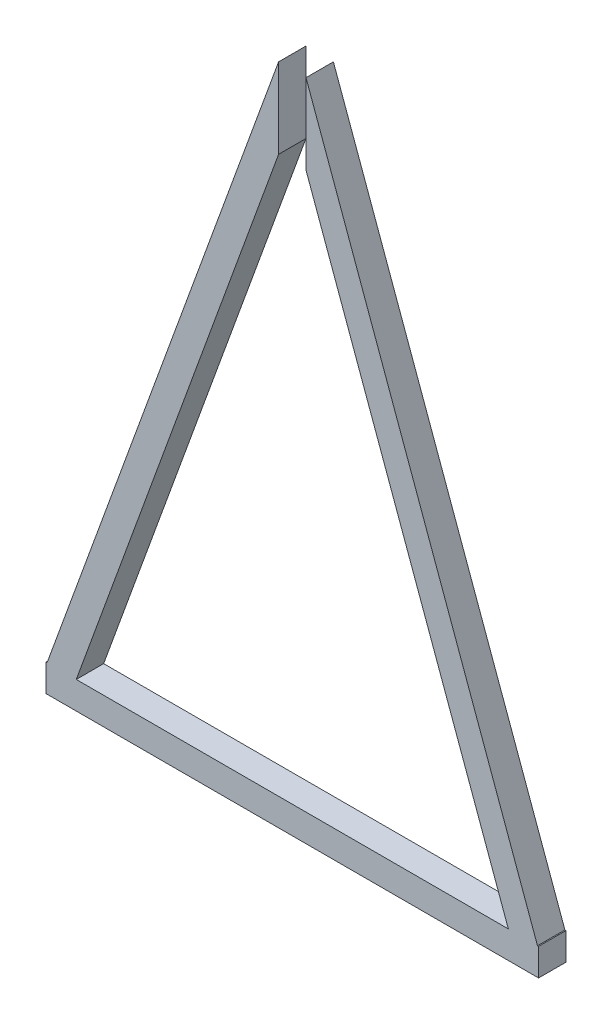
from build123d import *

# Parameters (mm, degrees)
CROQUIS1_W              = 1370
CROQUIS1_H              = 76.2
SALIENTE_EXTRUIR1_DEPTH = 76.2
SALIENTE_EXTRUIR2_DEPTH = 76.2


with BuildPart() as part:
    # Croquis1 → Saliente-Extruir1 (new body)
    with BuildSketch(Plane.XY):
        with Locations((685, 38.1)):
            Rectangle(CROQUIS1_W, CROQUIS1_H)
    extrude(amount=SALIENTE_EXTRUIR1_DEPTH)

    # Croquis2 → Saliente-Extruir2 (add)
    with BuildSketch(Plane.XY.offset(76.2)):
        Polygon((723.1, 1845.423164628), (723.1, 1622.629269336), (1285.954223436, 76.2), (1367.044569699, 76.2), align=None)
        Polygon((2.955430301, 76.2), (84.045776564, 76.2), (646.9, 1622.629269336), (646.9, 1845.423164628), align=None)
    extrude(amount=-SALIENTE_EXTRUIR2_DEPTH)


solid = part.part
